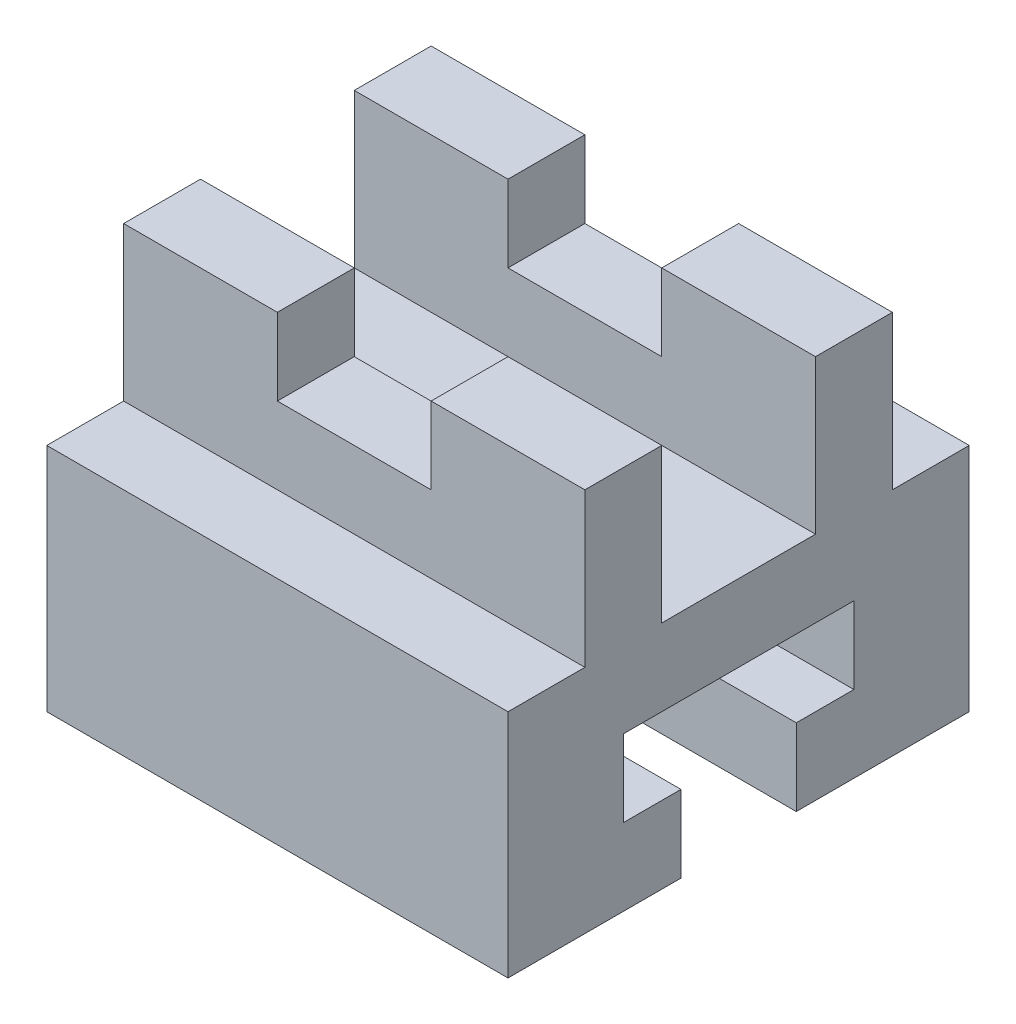
from build123d import *

# Parameters (mm, degrees)
SKETCH2_W           = 60
SKETCH2_H           = 50
BOSS_EXTRUDE2_DEPTH = 60
SKETCH4_W           = 10
SKETCH4_H           = 20
CUT_EXTRUDE2_DEPTH  = 60
CUT_EXTRUDE4_DEPTH  = 60
SKETCH8_W           = 20
SKETCH8_H           = 20
CUT_EXTRUDE5_DEPTH  = 60
SKETCH9_W           = 20
SKETCH9_H           = 10
CUT_EXTRUDE6_DEPTH  = 40


with BuildPart() as part:
    # Sketch2 → Boss-Extrude2 (new body)
    with BuildSketch(Plane.XY):
        with Locations((2.702702703, 14.797297297)):
            Rectangle(SKETCH2_W, SKETCH2_H)
    extrude(amount=BOSS_EXTRUDE2_DEPTH)

    # Sketch4 → Cut-Extrude2 (cut)
    with BuildSketch(Plane.ZY.offset(27.297297297)):
        with Locations((5, 29.797297297)):
            Rectangle(SKETCH4_W, SKETCH4_H)
        with Locations((55, 29.797297297)):
            Rectangle(SKETCH4_W, SKETCH4_H)
    extrude(amount=-CUT_EXTRUDE2_DEPTH, mode=Mode.SUBTRACT)

    # Sketch7 → Cut-Extrude4 (cut)
    with BuildSketch(Plane(origin=(32.702702703, 0, 0), x_dir=(0, 0, -1), z_dir=(1, 0, 0))):
        Polygon((-37.5, -10.202702703), (-37.5, -0.202702703), (-45, -0.202702703), (-45, 9.797297297), (-15, 9.797297297), (-15, -0.202702703), (-22.5, -0.202702703), (-22.5, -10.202702703), align=None)
    extrude(amount=-CUT_EXTRUDE4_DEPTH, mode=Mode.SUBTRACT)

    # Sketch8 → Cut-Extrude5 (cut)
    with BuildSketch(Plane.ZY.offset(27.297297297)):
        with Locations((30, 29.797297297)):
            Rectangle(SKETCH8_W, SKETCH8_H)
    extrude(amount=-CUT_EXTRUDE5_DEPTH, mode=Mode.SUBTRACT)

    # Sketch9 → Cut-Extrude6 (cut)
    with BuildSketch(Plane.XY.offset(50)):
        with Locations((2.702702703, 34.797297297)):
            Rectangle(SKETCH9_W, SKETCH9_H)
    extrude(amount=-CUT_EXTRUDE6_DEPTH, mode=Mode.SUBTRACT)


solid = part.part
